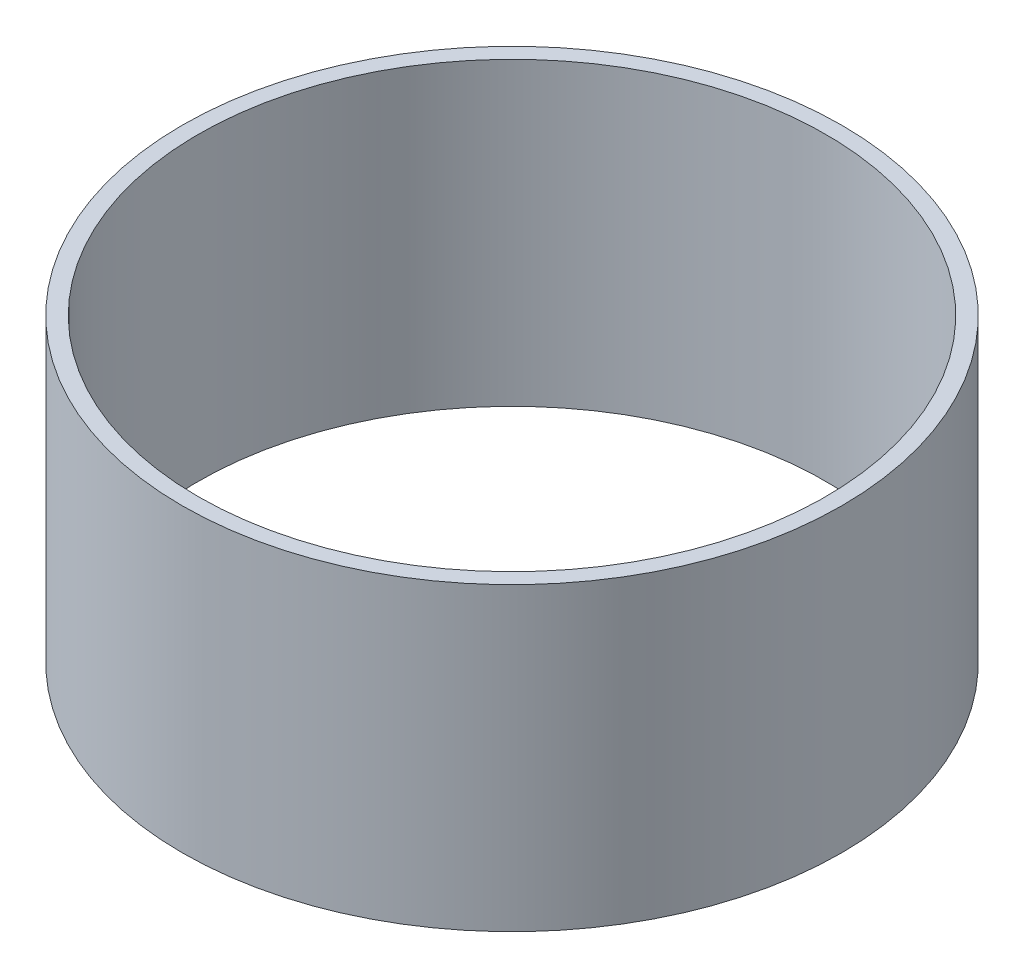
from build123d import *

# Parameters (mm, degrees)
SKETCH_1_R          = 735
EXTRUDE_1_DEPTH     = 670
SKETCH_2_R          = 699.5
CUT_EXTRUDE_1_DEPTH = 3178


with BuildPart() as part:
    # 草图1 → 凸台-拉伸1 (new body)
    with BuildSketch(Plane(origin=(0, 0, 0), x_dir=(1, 0, 0), z_dir=(0, 1, 0))):
        Circle(SKETCH_1_R)
    extrude(amount=EXTRUDE_1_DEPTH)

    # 草图2 → 切除-拉伸1 (cut)
    with BuildSketch(Plane(origin=(0, 670, 0), x_dir=(1, 0, 0), z_dir=(0, 1, 0))):
        Circle(SKETCH_2_R)
    extrude(amount=-CUT_EXTRUDE_1_DEPTH, mode=Mode.SUBTRACT)


solid = part.part
